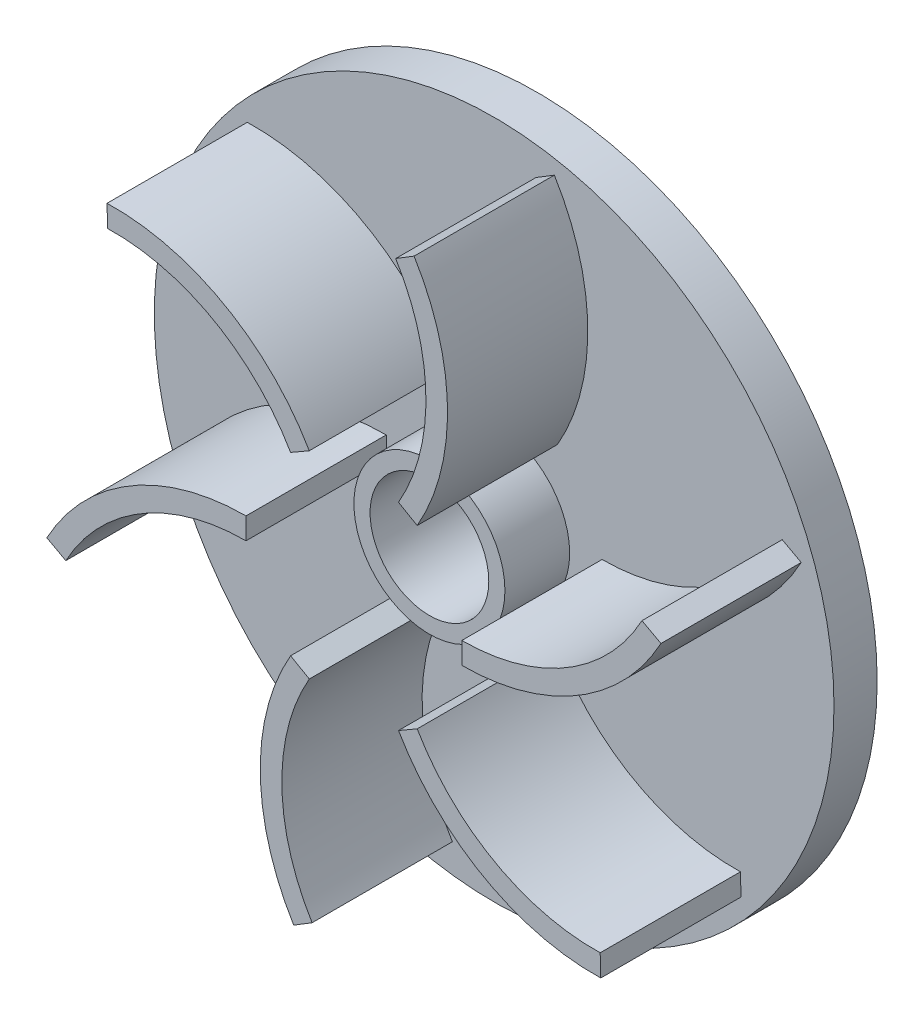
from build123d import *

# Parameters (mm, degrees)
SKETCH1_R                     = 31.5
EXTRUDE1_DEPTH                = 4
EXTRUDE_THIN1_DEPTH           = 13
CIRPATTERN7_COUNT             = 6
SKETCH3_R                     = 7
EXTRUDE2_DEPTH                = 6
M11_0_11_DIAMETER_HOLE1_D     = 11
M11_0_11_DIAMETER_HOLE1_DEPTH = 10
M11_0_11_DIAMETER_HOLE1_TIP   = 3.304733405


with BuildPart() as part:
    # Sketch1 → Extrude1 (new body)
    with BuildSketch(Plane.XY):
        Circle(SKETCH1_R)
    extrude(amount=EXTRUDE1_DEPTH)

    # Sketch2 → Extrude-Thin1 (add)
    with BuildSketch(Plane.XY.offset(4)):
        with BuildLine():
            ThreePointArc((10, -1), (20.741698661, 1.955169442), (28.460203071, 9.988960964))
            Line((28.460203071, 9.988960964), (26.702088493, 10.942393254))
            ThreePointArc((26.702088493, 10.942393254), (19.718679741, 3.673724733), (10, 1))
            Line((10, 1), (10, -1))
        make_face()
    extrude_thin1 = extrude(amount=EXTRUDE_THIN1_DEPTH)

    # CirPattern7: Extrude-Thin1 ×6 about axis
    cirpattern7_axis = Axis((0, 0, 0), (0, 0, 1))
    for i in range(1, CIRPATTERN7_COUNT):
        add(extrude_thin1.rotate(cirpattern7_axis, i * 360 / CIRPATTERN7_COUNT))

    # Sketch3 → Extrude2 (add)
    with BuildSketch(Plane.XY.offset(4)):
        Circle(SKETCH3_R)
    extrude(amount=EXTRUDE2_DEPTH)

    # M11.0 _11_ Diameter Hole1
    with Locations(Plane.XY.offset(10)):
        with Locations((0, 0)):
            Hole(M11_0_11_DIAMETER_HOLE1_D / 2, depth=M11_0_11_DIAMETER_HOLE1_DEPTH)
            with Locations((0, 0, -(M11_0_11_DIAMETER_HOLE1_DEPTH + M11_0_11_DIAMETER_HOLE1_TIP / 2))):  # 118° drill point
                Cone(0, M11_0_11_DIAMETER_HOLE1_D / 2, M11_0_11_DIAMETER_HOLE1_TIP, mode=Mode.SUBTRACT)


solid = part.part
